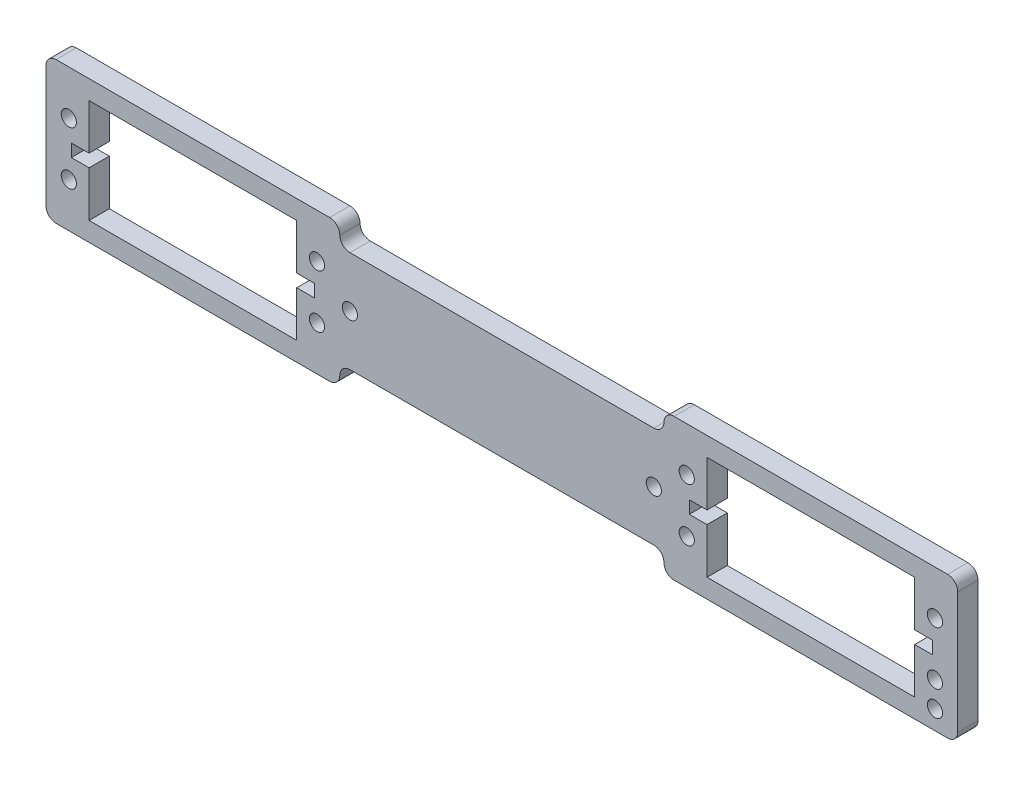
from build123d import *

# Parameters (mm, degrees)
SKETCH1_R           = 1.5
BOSS_EXTRUDE1_DEPTH = 4


with BuildPart() as part:
    # Sketch1 → Boss-Extrude1 (new body)
    with BuildSketch(Plane.XY):
        with BuildLine():
            Line((0, 2), (0, 26))
            ThreePointArc((0, 26), (0.585786438, 27.414213562), (2, 28))
            Line((2, 28), (56, 28))
            ThreePointArc((56, 28), (57.414213562, 27.414213562), (58, 26))
            ThreePointArc((58, 26), (58.585786438, 24.585786438), (60, 24))
            Line((60, 24), (120, 24))
            ThreePointArc((120, 24), (121.414213562, 24.585786438), (122, 26))
            ThreePointArc((122, 26), (122.585786438, 27.414213562), (124, 28))
            Line((124, 28), (178, 28))
            ThreePointArc((178, 28), (179.414213562, 27.414213562), (180, 26))
            Line((180, 26), (180, 2))
            ThreePointArc((180, 2), (179.414213562, 0.585786438), (178, 0))
            Line((178, 0), (124, 0))
            ThreePointArc((124, 0), (122.585786438, 0.585786438), (122, 2))
            ThreePointArc((122, 2), (121.414213562, 3.414213562), (120, 4))
            Line((120, 4), (60, 4))
            ThreePointArc((60, 4), (58.585786438, 3.414213562), (58, 2))
            ThreePointArc((58, 2), (57.414213562, 0.585786438), (56, 0))
            Line((56, 0), (2, 0))
            ThreePointArc((2, 0), (0.585786438, 0.585786438), (0, 2))
        make_face()
        with Locations((53.5, 19.25)):
            Circle(SKETCH1_R, mode=Mode.SUBTRACT)
        with Locations((53.5, 8.75)):
            Circle(SKETCH1_R, mode=Mode.SUBTRACT)
        with Locations((4.5, 19.25)):
            Circle(SKETCH1_R, mode=Mode.SUBTRACT)
        with Locations((4.5, 8.75)):
            Circle(SKETCH1_R, mode=Mode.SUBTRACT)
        with Locations((175.5, 19.25)):
            Circle(SKETCH1_R, mode=Mode.SUBTRACT)
        with Locations((175.5, 8.75)):
            Circle(SKETCH1_R, mode=Mode.SUBTRACT)
        with Locations((126.5, 19.25)):
            Circle(SKETCH1_R, mode=Mode.SUBTRACT)
        with Locations((126.5, 8.75)):
            Circle(SKETCH1_R, mode=Mode.SUBTRACT)
        with Locations((60, 14)):
            Circle(SKETCH1_R, mode=Mode.SUBTRACT)
        with Locations((120, 14)):
            Circle(SKETCH1_R, mode=Mode.SUBTRACT)
        with Locations((175.5, 3.75)):
            Circle(SKETCH1_R, mode=Mode.SUBTRACT)
        Polygon((8.5, 3.75), (8.5, 12.75), (5, 12.75), (5, 15.25), (8.5, 15.25), (8.5, 24.25), (49.5, 24.25), (49.5, 15.25), (53, 15.25), (53, 12.75), (49.5, 12.75), (49.5, 3.75), align=None, mode=Mode.SUBTRACT)
        Polygon((130.5, 3.75), (130.5, 12.75), (127, 12.75), (127, 15.25), (130.5, 15.25), (130.5, 24.25), (171.5, 24.25), (171.5, 15.25), (175, 15.25), (175, 12.75), (171.5, 12.75), (171.5, 3.75), align=None, mode=Mode.SUBTRACT)
    extrude(amount=BOSS_EXTRUDE1_DEPTH)


solid = part.part
